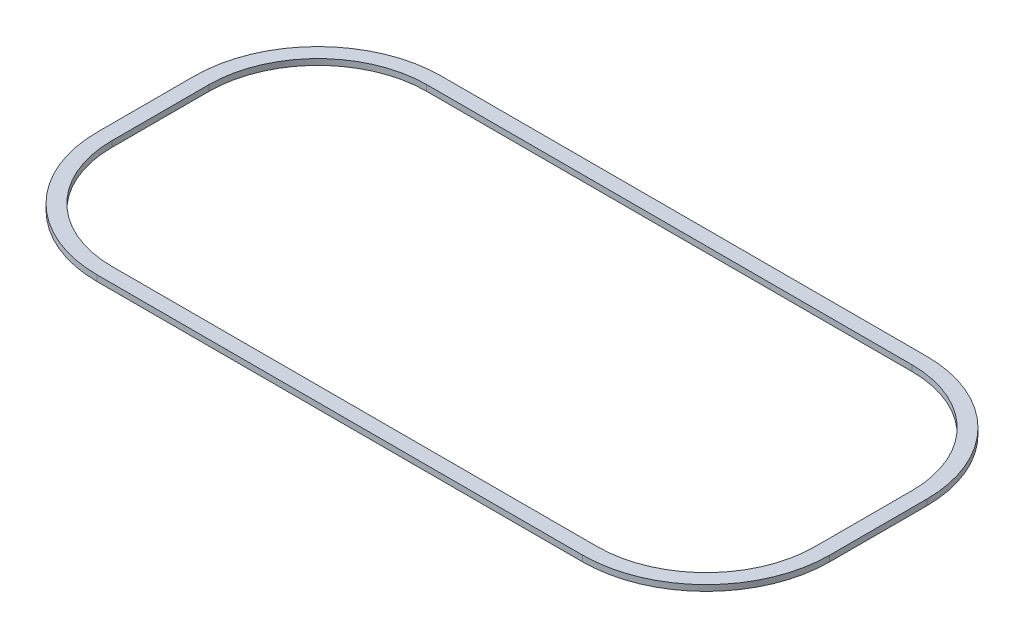
from build123d import *

# Parameters (mm, degrees)
BOSS_EXTRUDE1_DEPTH = 1.016


with BuildPart() as part:
    # Sketch1 → Boss-Extrude1 (new body)
    with BuildSketch(Plane(origin=(0, 0, 0), x_dir=(1, 0, 0), z_dir=(0, 1, 0))):
        with BuildLine():
            Line((0, 0), (83.82, 0))
            ThreePointArc((83.82, 0), (98.912902724, 6.251685004), (105.164587728, 21.344587728))
            Line((105.164587728, 21.344587728), (105.164587728, 38.108587728))
            ThreePointArc((105.164587728, 38.108587728), (98.912902724, 53.201490452), (83.82, 59.453175456))
            Line((83.82, 59.453175456), (0, 59.453175456))
            ThreePointArc((0, 59.453175456), (-15.092902724, 53.201490452), (-21.344587728, 38.108587728))
            Line((-21.344587728, 38.108587728), (-21.344587728, 21.344587728))
            ThreePointArc((-21.344587728, 21.344587728), (-15.092902724, 6.251685004), (0, 0))
        make_face()
        with BuildLine():
            Line((0, 2.54), (83.82, 2.54))
            ThreePointArc((83.82, 2.54), (97.1168515, 8.047736228), (102.624587728, 21.344587728))
            Line((102.624587728, 21.344587728), (102.624587728, 38.108587728))
            ThreePointArc((102.624587728, 38.108587728), (97.1168515, 51.405439228), (83.82, 56.913175456))
            Line((83.82, 56.913175456), (0, 56.913175456))
            ThreePointArc((0, 56.913175456), (-13.2968515, 51.405439228), (-18.804587728, 38.108587728))
            Line((-18.804587728, 38.108587728), (-18.804587728, 21.344587728))
            ThreePointArc((-18.804587728, 21.344587728), (-13.2968515, 8.047736228), (0, 2.54))
        make_face(mode=Mode.SUBTRACT)
    extrude(amount=BOSS_EXTRUDE1_DEPTH)


solid = part.part
